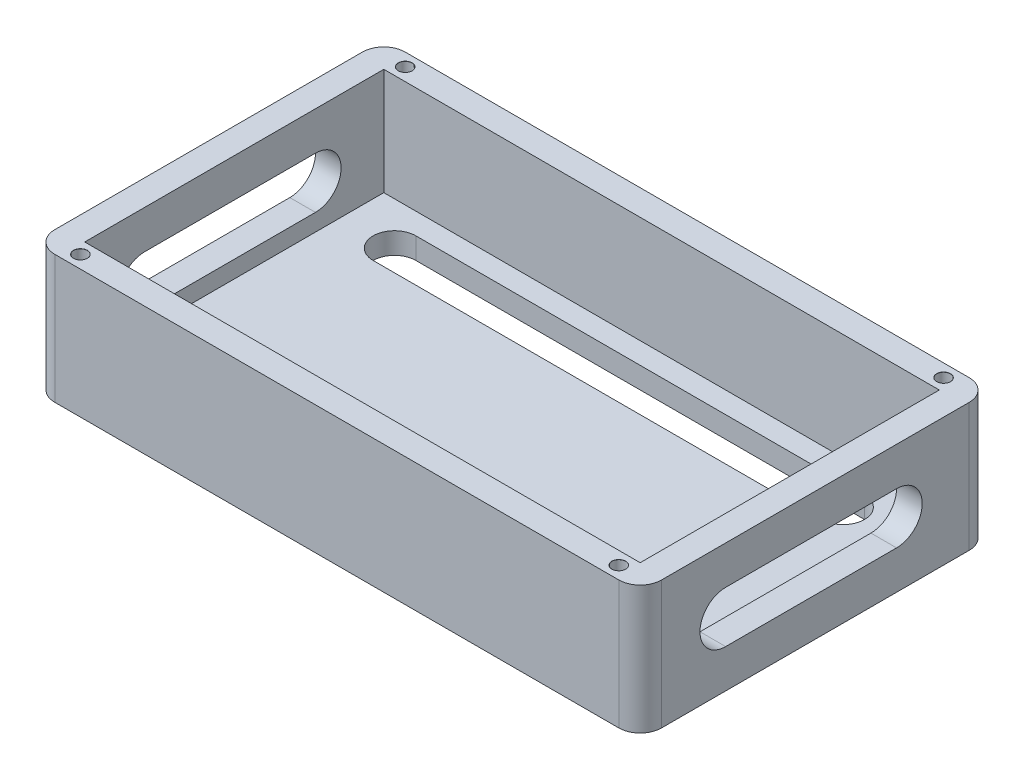
from build123d import *

# Parameters (mm, degrees)
SKETCH1_W                      = 142
SKETCH1_H                      = 82
BOSS_EXTRUDE1_DEPTH            = 30
SKETCH3_W                      = 130
SKETCH3_H                      = 70
CUT_EXTRUDE1_DEPTH             = 25
FILLET1_R                      = 5
M3_CLEARANCE_HOLE1_D           = 3.2
M3_CLEARANCE_HOLE1_CSINK_D     = 3.25
M3_CLEARANCE_HOLE1_CSINK_ANGLE = 90
CUT_EXTRUDE2_REACH             = 7
CUT_EXTRUDE3_DEPTH             = 143


with BuildPart() as part:
    # Sketch1 → Boss-Extrude1 (new body)
    with BuildSketch(Plane(origin=(0, 0, 0), x_dir=(1, 0, 0), z_dir=(0, 1, 0))):
        Rectangle(SKETCH1_W, SKETCH1_H)
    extrude(amount=BOSS_EXTRUDE1_DEPTH)

    # Sketch3 → Cut-Extrude1 (cut)
    with BuildSketch(Plane(origin=(0, 30, 0), x_dir=(1, 0, 0), z_dir=(0, 1, 0))):
        Rectangle(SKETCH3_W, SKETCH3_H)
    extrude(amount=-CUT_EXTRUDE1_DEPTH, mode=Mode.SUBTRACT)

    # Fillet1
    fillet1_edges = [part.edges().sort_by_distance(p)[0] for p in [
        (71, 15, 41),
        (-71, 15, 41),
        (-71, 15, -41),
        (71, 15, -41),
    ]]
    fillet(fillet1_edges, radius=FILLET1_R)

    # M3 Clearance Hole1 (through all)
    with Locations(Plane(origin=(0, 30, 0), x_dir=(1, 0, 0), z_dir=(0, 1, 0))):
        with Locations((63, -38), (63, 38), (-63, 38), (-63, -38)):
            CounterSinkHole(M3_CLEARANCE_HOLE1_D / 2, M3_CLEARANCE_HOLE1_CSINK_D / 2, counter_sink_angle=M3_CLEARANCE_HOLE1_CSINK_ANGLE)

    # Sketch6 → Cut-Extrude2 (cut, up to next)
    with BuildSketch(Plane(origin=(0, 5, 0), x_dir=(1, 0, 0), z_dir=(0, 1, 0)), mode=Mode.PRIVATE) as cut_extrude2_sk1:
        with BuildLine():
            Line((52.5, -30), (-52.5, -30))
            ThreePointArc((-52.5, -30), (-57.5, -25), (-52.5, -20))
            Line((-52.5, -20), (52.5, -20))
            ThreePointArc((52.5, -20), (57.5, -25), (52.5, -30))
        make_face()
    cut_extrude2_tool1 = extrude(cut_extrude2_sk1.sketch, amount=-CUT_EXTRUDE2_REACH, mode=Mode.PRIVATE) & part.part
    add(cut_extrude2_tool1.solids().sort_by_distance((0, 5, 25))[0], mode=Mode.SUBTRACT)
    # Sketch6 → Cut-Extrude2 (cut, up to next)
    with BuildSketch(Plane(origin=(0, 5, 0), x_dir=(1, 0, 0), z_dir=(0, 1, 0)), mode=Mode.PRIVATE) as cut_extrude2_sk2:
        with BuildLine():
            Line((52.5, 20), (-52.5, 20))
            ThreePointArc((-52.5, 20), (-57.5, 25), (-52.5, 30))
            Line((-52.5, 30), (52.5, 30))
            ThreePointArc((52.5, 30), (57.5, 25), (52.5, 20))
        make_face()
    cut_extrude2_tool2 = extrude(cut_extrude2_sk2.sketch, amount=-CUT_EXTRUDE2_REACH, mode=Mode.PRIVATE) & part.part
    add(cut_extrude2_tool2.solids().sort_by_distance((0, 5, -25))[0], mode=Mode.SUBTRACT)

    # Sketch7 → Cut-Extrude3 (cut, through all)
    with BuildSketch(Plane(origin=(71, 0, 0), x_dir=(0, 0, -1), z_dir=(1, 0, 0))):
        with BuildLine():
            Line((-21, 21), (19, 21))
            ThreePointArc((19, 21), (25, 15), (19, 9))
            Line((19, 9), (-21, 9))
            ThreePointArc((-21, 9), (-27, 15), (-21, 21))
        make_face()
    extrude(amount=-CUT_EXTRUDE3_DEPTH, mode=Mode.SUBTRACT)


solid = part.part
